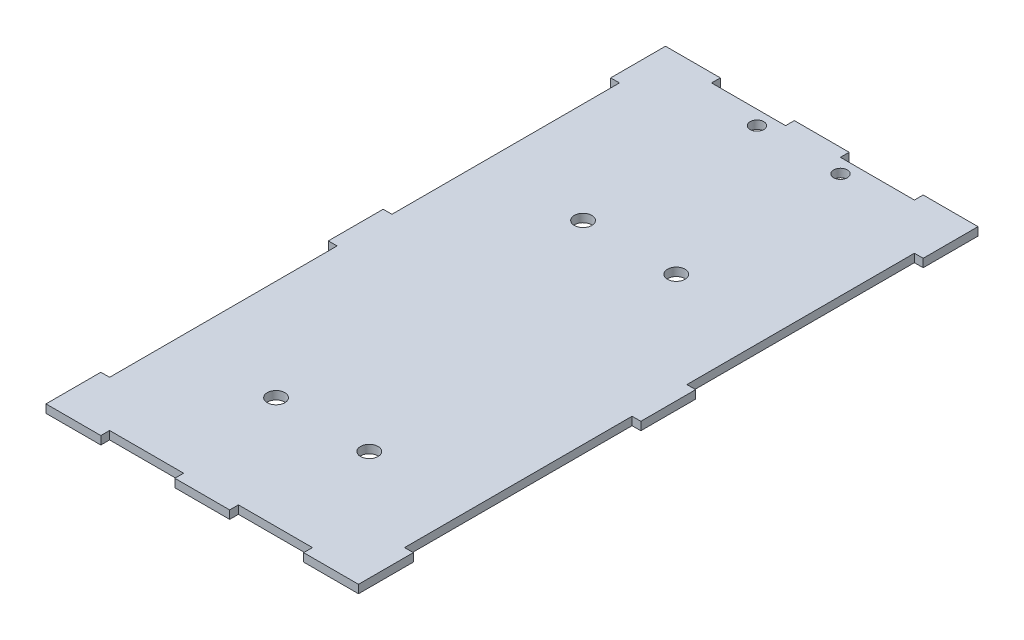
from build123d import *

# Parameters (mm, degrees)
SKETCH1_R           = 1.25
SKETCH1_R_2         = 1.6
BOSS_EXTRUDE1_DEPTH = 1.5


with BuildPart() as part:
    # Sketch1 → Boss-Extrude1 (new body)
    with BuildSketch(Plane(origin=(0, 0, 0), x_dir=(1, 0, 0), z_dir=(0, 1, 0))):
        Polygon((57, 0), (57, 10), (55.4, 10), (55.4, 51.5), (57, 51.5), (57, 61.5), (55.4, 61.5), (55.4, 103), (57, 103), (57, 113), (47, 113), (47, 111.4), (33.5, 111.4), (33.5, 113), (23.5, 113), (23.5, 111.4), (10, 111.4), (10, 113), (0, 113), (0, 103), (1.6, 103), (1.6, 61.5), (0, 61.5), (0, 51.5), (1.6, 51.5), (1.6, 10), (0, 10), (0, 0), (10, 0), (10, 1.6), (23.5, 1.6), (23.5, 0), (33.5, 0), (33.5, 1.6), (47, 1.6), (47, 0), align=None)
        with Locations((20.88, 108.8)):
            Circle(SKETCH1_R, mode=Mode.SUBTRACT)
        with Locations((36.12, 108.8)):
            Circle(SKETCH1_R, mode=Mode.SUBTRACT)
        with Locations((20, 77.964629758)):
            Circle(SKETCH1_R_2, mode=Mode.SUBTRACT)
        with Locations((37, 77.964629758)):
            Circle(SKETCH1_R_2, mode=Mode.SUBTRACT)
        with Locations((20, 21.964629758)):
            Circle(SKETCH1_R_2, mode=Mode.SUBTRACT)
        with Locations((37, 21.964629758)):
            Circle(SKETCH1_R_2, mode=Mode.SUBTRACT)
    extrude(amount=BOSS_EXTRUDE1_DEPTH)


solid = part.part
